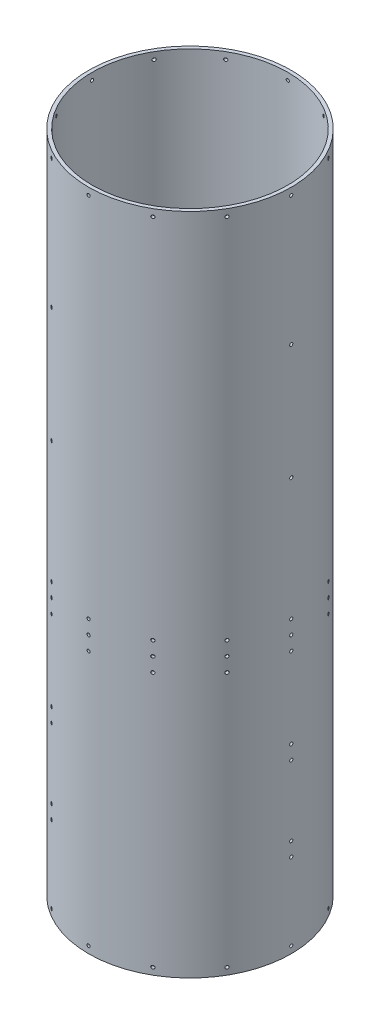
from build123d import *

# Parameters (mm, degrees)
SKETCH1_R           = 92.075
SKETCH1_R_2         = 88.9
BOSS_EXTRUDE1_DEPTH = 301.625
SKETCH3_R           = 1.4351
CUT_EXTRUDE1_DEPTH  = 34.798
CIRPATTERN1_COUNT   = 12
SKETCH4_R           = 1.4351
CUT_EXTRUDE2_DEPTH  = 55.372
CIRPATTERN2_COUNT   = 3


with BuildPart() as part:
    # Sketch1 → Boss-Extrude1 (new body, symmetric)
    with BuildSketch(Plane(origin=(0, 0, 0), x_dir=(1, 0, 0), z_dir=(0, 1, 0))):
        Circle(SKETCH1_R)
        Circle(SKETCH1_R_2, mode=Mode.SUBTRACT)
    extrude(amount=BOSS_EXTRUDE1_DEPTH, both=True)

    # Sketch3 → Cut-Extrude1 (cut)
    with BuildSketch(Plane(origin=(92.075, 0, 0), x_dir=(0, 0, -1), z_dir=(1, 0, 0))):
        with Locations((0, -295.275)):
            Circle(SKETCH3_R)
        with Locations((0, 295.275)):
            Circle(SKETCH3_R)
        with Locations((0, -63.373)):
            Circle(SKETCH3_R)
        with Locations((0, -50.673)):
            Circle(SKETCH3_R)
        with Locations((0, -37.973)):
            Circle(SKETCH3_R)
    cut_extrude1 = extrude(amount=-CUT_EXTRUDE1_DEPTH, mode=Mode.SUBTRACT)

    # CirPattern1: Cut-Extrude1 ×12 about axis
    cirpattern1_axis = Axis((0, 301.625, 0), (0, -1, 0))
    for i in range(1, CIRPATTERN1_COUNT):
        add(cut_extrude1.rotate(cirpattern1_axis, i * 360 / CIRPATTERN1_COUNT), mode=Mode.SUBTRACT)

    # Sketch4 → Cut-Extrude2 (cut)
    with BuildSketch(Plane(origin=(92.075, 0, 0), x_dir=(0, 0, -1), z_dir=(1, 0, 0))):
        with Locations((0, -225.425)):
            Circle(SKETCH4_R)
        with Locations((0, -212.725)):
            Circle(SKETCH4_R)
        with Locations((0, -149.225)):
            Circle(SKETCH4_R)
        with Locations((0, -136.525)):
            Circle(SKETCH4_R)
        with Locations((0, 177.927)):
            Circle(SKETCH4_R)
        with Locations((0, 73.025)):
            Circle(SKETCH4_R)
    cut_extrude2 = extrude(amount=-CUT_EXTRUDE2_DEPTH, mode=Mode.SUBTRACT)

    # CirPattern2: Cut-Extrude2 ×3 about axis
    cirpattern2_axis = Axis((0, 301.625, 0), (0, -1, 0))
    for i in range(1, CIRPATTERN2_COUNT):
        add(cut_extrude2.rotate(cirpattern2_axis, i * 360 / CIRPATTERN2_COUNT), mode=Mode.SUBTRACT)


solid = part.part
